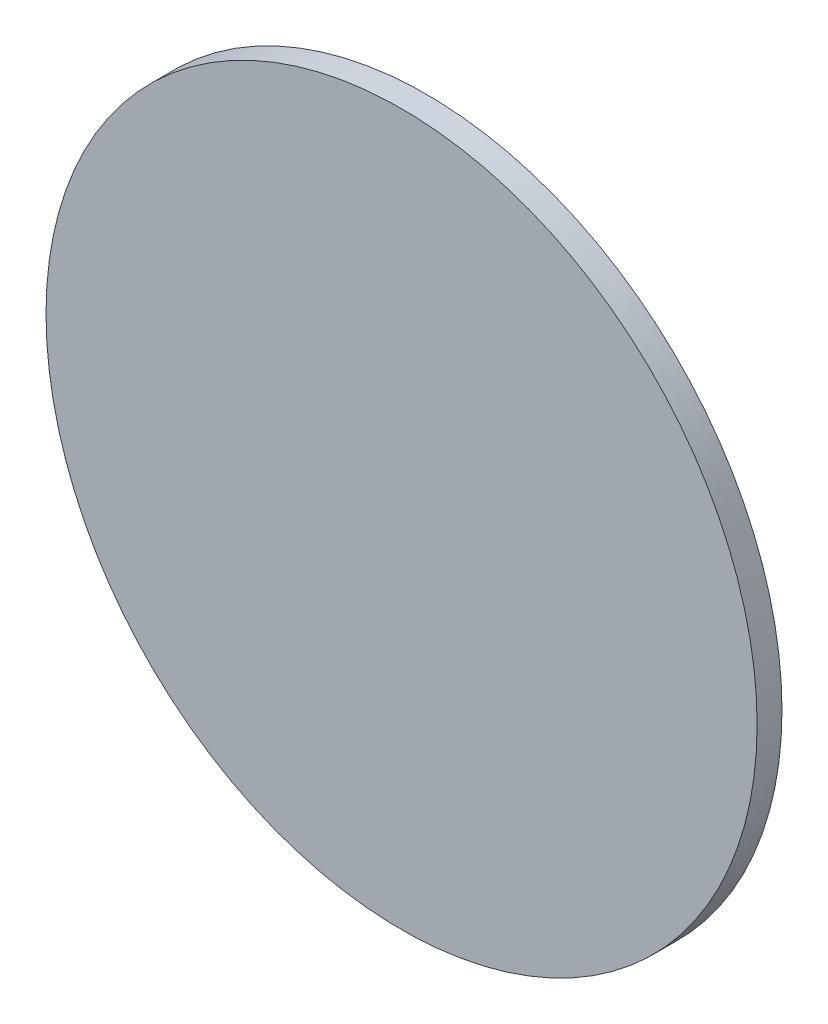
from build123d import *

# Parameters (mm, degrees)
ESQUISSE1_R        = 143
BOSS_EXTRU_1_DEPTH = 10


with BuildPart() as part:
    # Esquisse1 → Boss.-Extru.1 (new body)
    with BuildSketch(Plane.XY):
        Circle(ESQUISSE1_R)
    extrude(amount=BOSS_EXTRU_1_DEPTH)


solid = part.part
